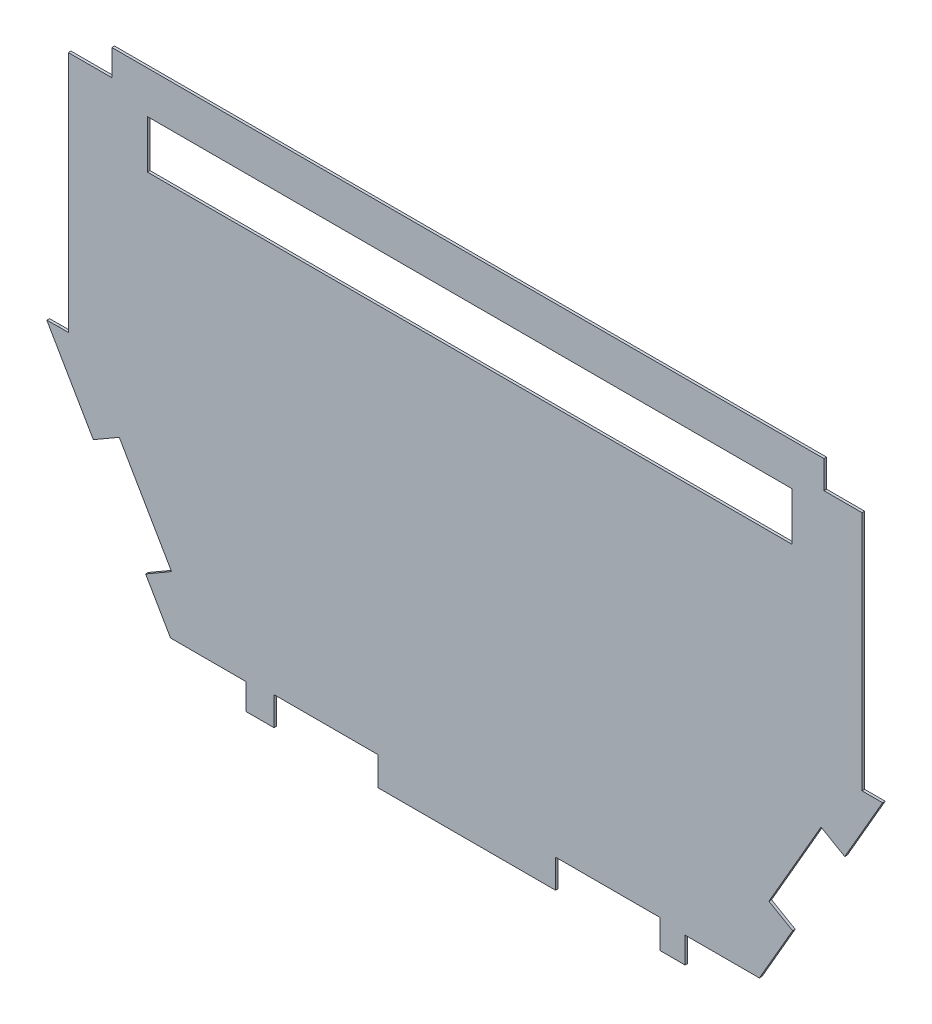
from build123d import *

# Parameters (mm, degrees)
BOSS_EXTRUDE1_DEPTH = 2
CUT_EXTRUDE1_DEPTH  = 103
CUT_EXTRUDE2_DEPTH  = 103
SKETCH8_W           = 494.939291997
SKETCH8_H           = 36.91417239
CUT_EXTRUDE3_DEPTH  = 103
SKETCH9_W           = 80
SKETCH9_H           = 22
CUT_EXTRUDE4_DEPTH  = 103
SKETCH10_W          = 80
SKETCH10_H          = 22
CUT_EXTRUDE5_DEPTH  = 10
CUT_EXTRUDE26_DEPTH = 50
SKETCH20_W          = 123.508554763
SKETCH20_H          = 186.038500142
CUT_EXTRUDE27_DEPTH = 50


with BuildPart() as part:
    # Sketch4 → Boss-Extrude1 (new body)
    with BuildSketch(Plane.XY):
        Polygon((-808.497250172, 502.106800376), (-261.98073047, 502.105226222), (-261.98073047, 480.770733626), (-232.677404129, 480.770733626), (-232.677404129, 452.134951617), (-212.25184889, 452.134951617), (-212.192076558, 346.868854324), (-232.677404129, 346.868854324), (-232.677404129, 295.854721303), (-216.917061767, 295.854721303), (-311.499917796, 132.032409135), (-368.546557809, 132.032409135), (-368.546557809, 112.12343356), (-705.513477189, 112.12343356), (-705.513477189, 132.032409135), (-763.511495449, 132.032409135), (-858.513561886, 295.854721303), (-842.744632695, 296.076779874), (-842.744632695, 346.305423028), (-862.968217561, 346.305423028), (-862.968217561, 452.932027611), (-841.983456779, 452.932027611), (-841.983456779, 482.016653843), (-813.304156304, 482.016653843), (-808.497250172, 482.016653843), align=None)
    extrude(amount=BOSS_EXTRUDE1_DEPTH)

    # Sketch6 → Cut-Extrude1 (cut)
    with BuildSketch(Plane.XY.offset(2)):
        Polygon((-822.786730896, 234.247092346), (-802.890229544, 245.785256582), (-762.757484374, 176.580034487), (-782.653985726, 165.041870251), align=None)
    extrude(amount=-CUT_EXTRUDE1_DEPTH, mode=Mode.SUBTRACT)

    # Sketch7 → Cut-Extrude2 (cut)
    with BuildSketch(Plane(origin=(0, 0, 0), x_dir=(-1, 0, 0), z_dir=(0, 0, -1))):
        Polygon((245.988579257, 245.501375956), (264.175112736, 256.001375956), (304.175112736, 186.719343654), (285.988579257, 176.219343654), align=None)
    extrude(amount=-CUT_EXTRUDE2_DEPTH, mode=Mode.SUBTRACT)

    # Sketch8 → Cut-Extrude3 (cut)
    with BuildSketch(Plane.XY.offset(2)):
        with Locations((-533.868102369, 451.361565469)):
            Rectangle(SKETCH8_W, SKETCH8_H)
    extrude(amount=-CUT_EXTRUDE3_DEPTH, mode=Mode.SUBTRACT)

    # Sketch9 → Cut-Extrude4 (cut)
    with BuildSketch(Plane(origin=(0, 0, 0), x_dir=(-1, 0, 0), z_dir=(0, 0, -1))):
        with Locations((427.942047779, 123.12343356)):
            Rectangle(SKETCH9_W, SKETCH9_H)
    extrude(amount=-CUT_EXTRUDE4_DEPTH, mode=Mode.SUBTRACT)

    # Sketch10 → Cut-Extrude5 (cut)
    with BuildSketch(Plane(origin=(0, 0, 0), x_dir=(-1, 0, 0), z_dir=(0, 0, -1))):
        with Locations((644.102693804, 123.12343356)):
            Rectangle(SKETCH10_W, SKETCH10_H)
    extrude(amount=-CUT_EXTRUDE5_DEPTH, mode=Mode.SUBTRACT)

    # Sketch18 → Cut-Extrude26 (cut)
    with BuildSketch(Plane(origin=(0, 0, 0), x_dir=(-1, 0, 0), z_dir=(0, 0, -1))):
        Polygon((232.677404129, 337.860322108), (232.677404129, 496.22384363), (155.712939473, 496.22384363), (155.712939473, 334.151575125), (232.677404129, 334.151575125), align=None)
    extrude(amount=-CUT_EXTRUDE26_DEPTH, mode=Mode.SUBTRACT)

    # Sketch20 → Cut-Extrude27 (cut)
    with BuildSketch(Plane(origin=(0, 0, 0), x_dir=(-1, 0, 0), z_dir=(0, 0, -1))):
        with Locations((903.737734161, 388.997403772)):
            Rectangle(SKETCH20_W, SKETCH20_H)
    extrude(amount=-CUT_EXTRUDE27_DEPTH, mode=Mode.SUBTRACT)


solid = part.part
